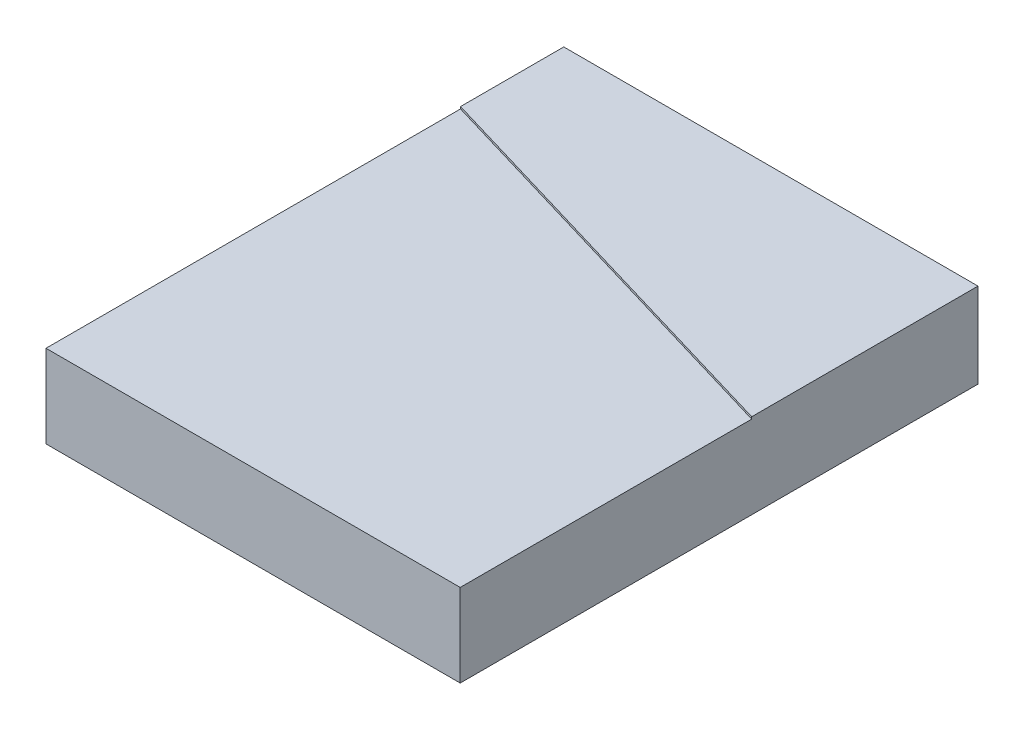
from build123d import *

# Parameters (mm, degrees)
SKETCH_1_W      = 20
SKETCH_1_H      = 25
EXTRUDE_1_DEPTH = 4
EXTRUDE_2_DEPTH = 0.1


with BuildPart() as part:
    # Эскиз1 → Бобышка-Вытянуть1 (new body)
    with BuildSketch(Plane(origin=(0, 0, 0), x_dir=(1, 0, 0), z_dir=(0, 1, 0))):
        Rectangle(SKETCH_1_W, SKETCH_1_H)
    extrude(amount=EXTRUDE_1_DEPTH)

    # Эскиз2 → Бобышка-Вытянуть2 (add)
    with BuildSketch(Plane(origin=(0, 4, 0), x_dir=(1, 0, 0), z_dir=(0, 1, 0))):
        Polygon((-10, 12.5), (-10, 7.514646674), (10, 1.574499656), (10, 12.5), align=None)
    extrude(amount=EXTRUDE_2_DEPTH)


solid = part.part
